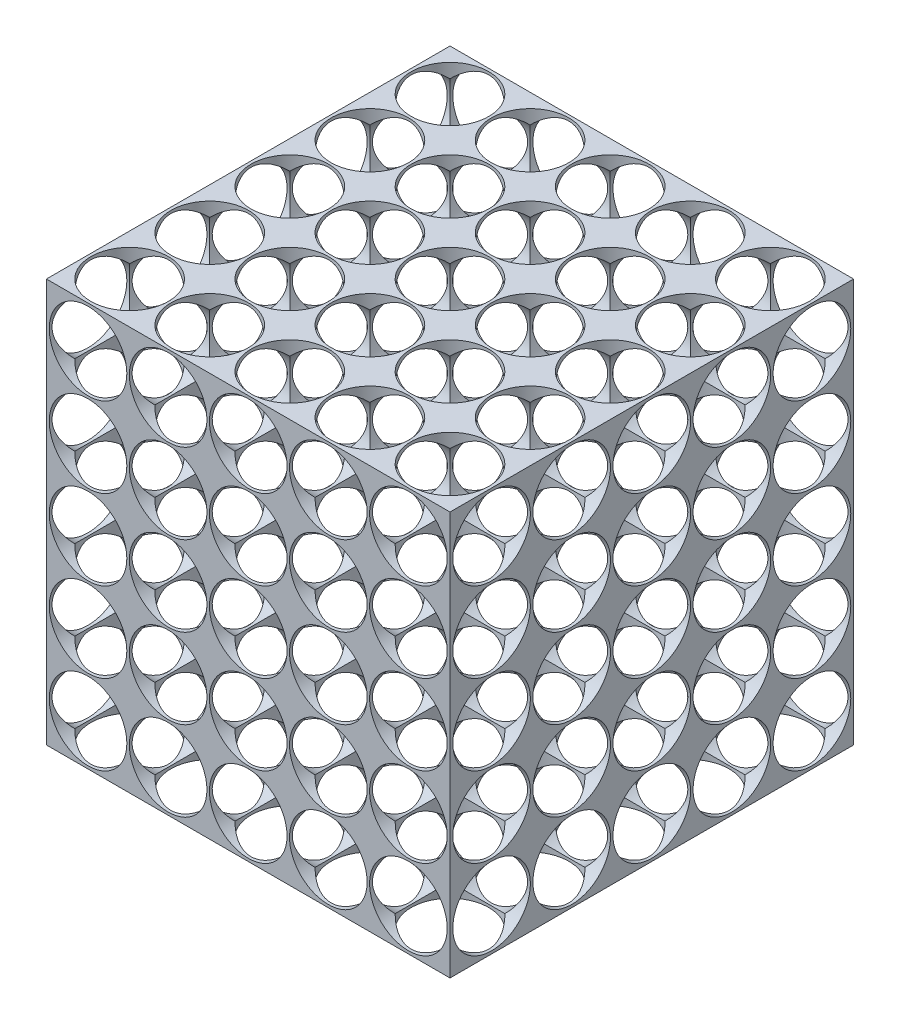
from build123d import *

# Parameters (mm, degrees)
SKETCH1_W                    = 82.55
SKETCH1_H                    = 82.55
BOSS_EXTRUDE1_DEPTH          = 82.55
F_5_8_0_625_DIAMETER_HOLE1_D = 15.875
LPATTERN1_COUNT              = 5
LPATTERN1_PITCH              = 16.383
LPATTERN1_COUNT_DIR2         = 5
LPATTERN1_PITCH_DIR2         = 16.383
F_5_8_0_625_DIAMETER_HOLE2_D = 15.875
LPATTERN3_COUNT              = 5
LPATTERN3_PITCH              = 16.383
LPATTERN3_COUNT_DIR2         = 5
LPATTERN3_PITCH_DIR2         = 16.383
F_5_8_0_625_DIAMETER_HOLE3_D = 15.875
LPATTERN4_COUNT              = 5
LPATTERN4_PITCH              = 16.383
LPATTERN4_COUNT_DIR2         = 5
LPATTERN4_PITCH_DIR2         = 16.383


with BuildPart() as part:
    # Sketch1 → Boss-Extrude1 (new body)
    with BuildSketch(Plane(origin=(0, 0, 0), x_dir=(1, 0, 0), z_dir=(0, 1, 0))):
        with Locations((41.275, 41.275)):
            Rectangle(SKETCH1_W, SKETCH1_H)
    extrude(amount=BOSS_EXTRUDE1_DEPTH)

    # 5/8 (0.625) Diameter Hole1 (through all)
    with Locations(Plane(origin=(0, 82.55, 0), x_dir=(1, 0, 0), z_dir=(0, 1, 0))):
        with Locations((8.509, 8.509)):
            f_5_8_0_625_diameter_hole1 = Hole(F_5_8_0_625_DIAMETER_HOLE1_D / 2)

    # LPattern1: 5_8 _0.625_ Diameter Hole1 5 × 5
    with Locations(*[(j * LPATTERN1_PITCH_DIR2, 0, -i * LPATTERN1_PITCH) for i in range(LPATTERN1_COUNT) for j in range(LPATTERN1_COUNT_DIR2) if (i, j) != (0, 0)]):
        add(f_5_8_0_625_diameter_hole1, mode=Mode.SUBTRACT)

    # 5/8 (0.625) Diameter Hole2 (through all)
    with Locations(Plane.XY):
        with Locations((8.509, 8.509)):
            f_5_8_0_625_diameter_hole2 = Hole(F_5_8_0_625_DIAMETER_HOLE2_D / 2)

    # LPattern3: 5_8 _0.625_ Diameter Hole2 5 × 5
    with Locations(*[(j * LPATTERN3_PITCH_DIR2, i * LPATTERN3_PITCH, 0) for i in range(LPATTERN3_COUNT) for j in range(LPATTERN3_COUNT_DIR2) if (i, j) != (0, 0)]):
        add(f_5_8_0_625_diameter_hole2, mode=Mode.SUBTRACT)

    # 5/8 (0.625) Diameter Hole3 (through all)
    with Locations(Plane(origin=(82.55, 0, 0), x_dir=(0, 0, -1), z_dir=(1, 0, 0))):
        with Locations((8.509, 8.509)):
            f_5_8_0_625_diameter_hole3 = Hole(F_5_8_0_625_DIAMETER_HOLE3_D / 2)

    # LPattern4: 5_8 _0.625_ Diameter Hole3 5 × 5
    with Locations(*[(0, i * LPATTERN4_PITCH, -j * LPATTERN4_PITCH_DIR2) for i in range(LPATTERN4_COUNT) for j in range(LPATTERN4_COUNT_DIR2) if (i, j) != (0, 0)]):
        add(f_5_8_0_625_diameter_hole3, mode=Mode.SUBTRACT)


solid = part.part
